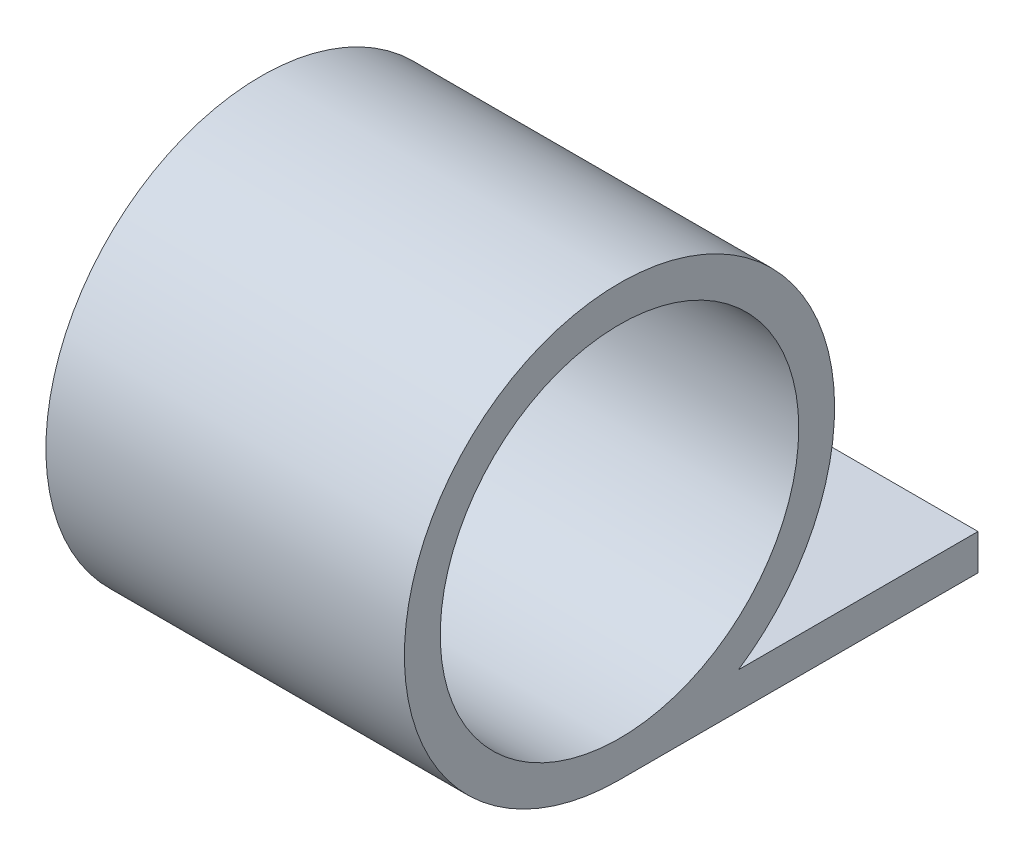
from build123d import *

# Parameters (mm, degrees)
SKETCH1_R           = 5
BOSS_EXTRUDE1_DEPTH = 10


with BuildPart() as part:
    # Sketch1 → Boss-Extrude1 (new body)
    with BuildSketch(Plane(origin=(0, 0, 0), x_dir=(0, 0, -1), z_dir=(1, 0, 0))):
        with BuildLine():
            Line((10, -5), (3.31662479, -5))
            ThreePointArc((3.31662479, -5), (-1.732050808, 5.744562647), (0, -6))
            Line((0, -6), (10, -6))
            Line((10, -6), (10, -5))
        make_face()
        Circle(SKETCH1_R, mode=Mode.SUBTRACT)
    extrude(amount=BOSS_EXTRUDE1_DEPTH)


solid = part.part
